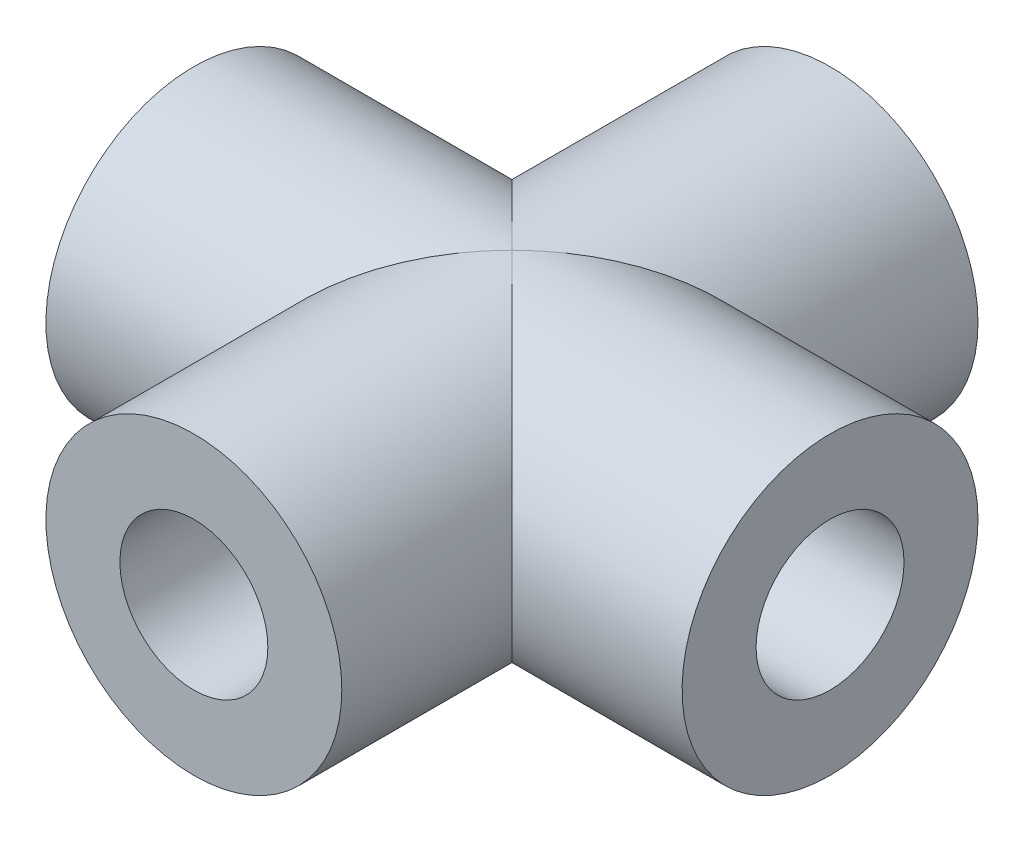
from build123d import *

# Parameters (mm, degrees)
SKETCH3_R           = 12.7
SKETCH3_R_2         = 6.35
BOSS_EXTRUDE1_DEPTH = 27.305
SKETCH4_R           = 12.7
SKETCH4_R_2         = 6.35
BOSS_EXTRUDE2_DEPTH = 27.305


with BuildPart() as part:
    # Sketch3 → Boss-Extrude1 (new body, symmetric)
    with BuildSketch(Plane.XY):
        Circle(SKETCH3_R)
        Circle(SKETCH3_R_2, mode=Mode.SUBTRACT)
    extrude(amount=BOSS_EXTRUDE1_DEPTH, both=True)

    # Sketch4 → Boss-Extrude2 (add, symmetric)
    with BuildSketch(Plane(origin=(0, 0, 0), x_dir=(0, 0, -1), z_dir=(1, 0, 0))):
        Circle(SKETCH4_R)
        Circle(SKETCH4_R_2, mode=Mode.SUBTRACT)
    extrude(amount=BOSS_EXTRUDE2_DEPTH, both=True)


solid = part.part
